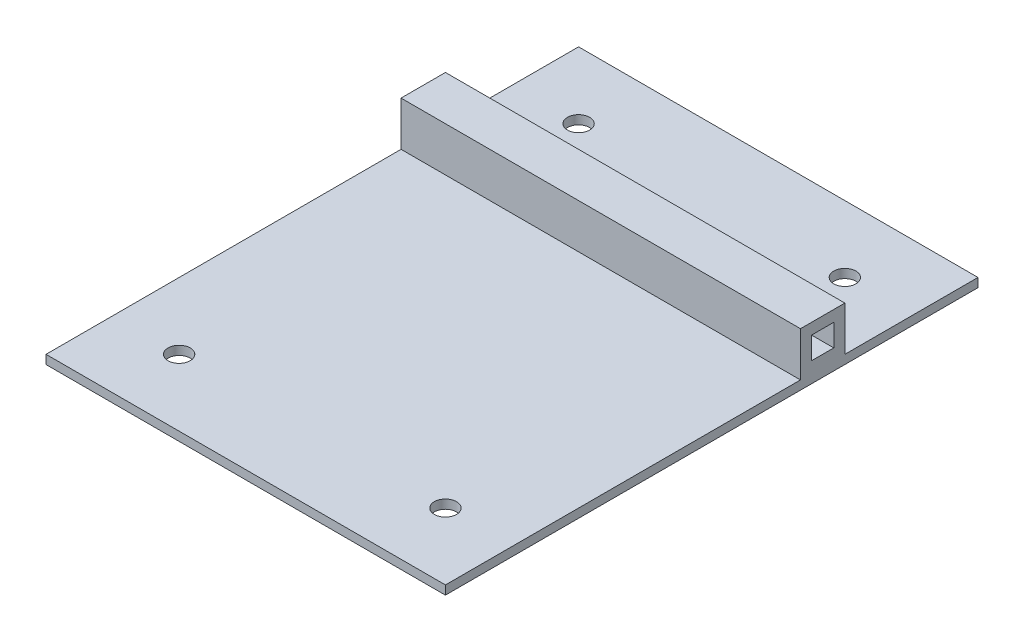
from build123d import *

# Parameters (mm, degrees)
SKETCH1_W           = 114.3
SKETCH1_H           = 152.4
BOSS_EXTRUDE1_DEPTH = 2.54
SKETCH2_W           = 114.3
SKETCH2_H           = 12.7
BOSS_EXTRUDE2_DEPTH = 12.7
SKETCH3_W           = 6.35
SKETCH3_H           = 6.35
CUT_EXTRUDE1_DEPTH  = 115.3
SKETCH4_R           = 3.175
CUT_EXTRUDE2_DEPTH  = 3.54


with BuildPart() as part:
    # Sketch1 → Boss-Extrude1 (new body)
    with BuildSketch(Plane(origin=(0, 0, 0), x_dir=(1, 0, 0), z_dir=(0, 1, 0))):
        Rectangle(SKETCH1_W, SKETCH1_H)
    extrude(amount=BOSS_EXTRUDE1_DEPTH)

    # Sketch2 → Boss-Extrude2 (add)
    with BuildSketch(Plane(origin=(0, 2.54, 0), x_dir=(1, 0, 0), z_dir=(0, 1, 0))):
        with Locations((0, 31.75)):
            Rectangle(SKETCH2_W, SKETCH2_H)
    extrude(amount=BOSS_EXTRUDE2_DEPTH)

    # Sketch3 → Cut-Extrude1 (cut, through all)
    with BuildSketch(Plane.ZY.offset(57.15)):
        with Locations((-31.75, 8.89)):
            Rectangle(SKETCH3_W, SKETCH3_H)
    extrude(amount=-CUT_EXTRUDE1_DEPTH, mode=Mode.SUBTRACT)

    # Sketch4 → Cut-Extrude2 (cut, through all)
    with BuildSketch(Plane(origin=(0, 2.54, 0), x_dir=(1, 0, 0), z_dir=(0, 1, 0))):
        with Locations((-38.1, 57.15)):
            Circle(SKETCH4_R)
        with Locations((38.1, 57.15)):
            Circle(SKETCH4_R)
        with Locations((-38.1, -57.15)):
            Circle(SKETCH4_R)
        with Locations((38.1, -57.15)):
            Circle(SKETCH4_R)
    extrude(amount=-CUT_EXTRUDE2_DEPTH, mode=Mode.SUBTRACT)


solid = part.part
